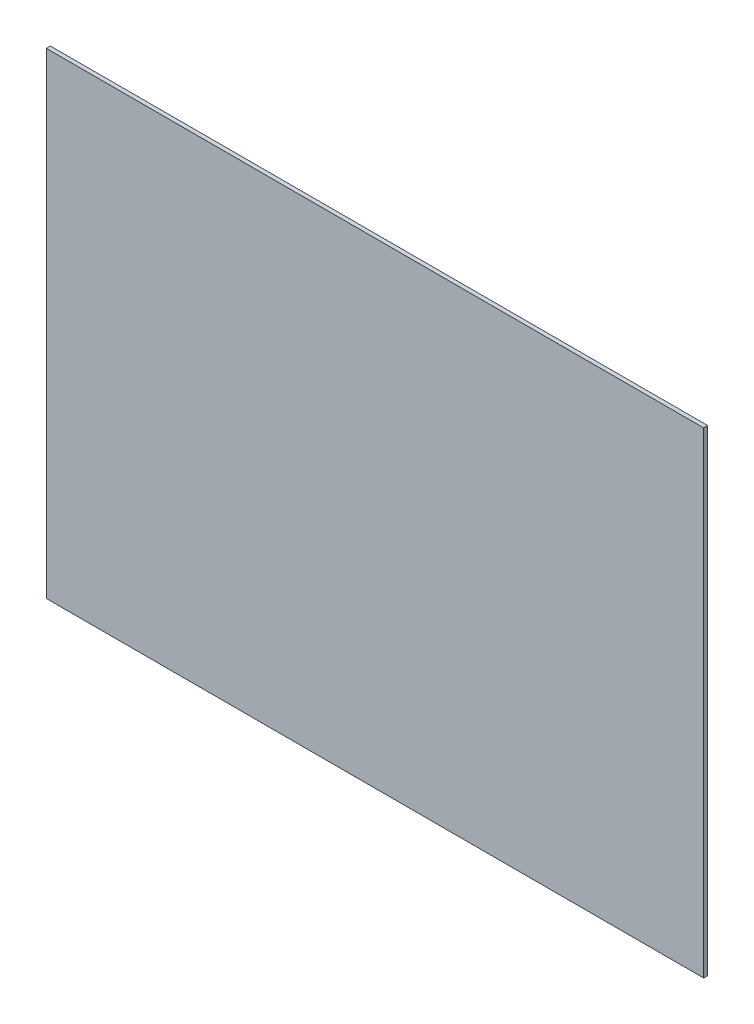
from build123d import *

# Parameters (mm, degrees)
SKETCH1_W           = 909.2
SKETCH1_H           = 659
BOSS_EXTRUDE1_DEPTH = 2.794


with BuildPart() as part:
    # Sketch1 → Boss-Extrude1 (new body, symmetric)
    with BuildSketch(Plane.XY):
        Rectangle(SKETCH1_W, SKETCH1_H)
    extrude(amount=BOSS_EXTRUDE1_DEPTH, both=True)


solid = part.part
